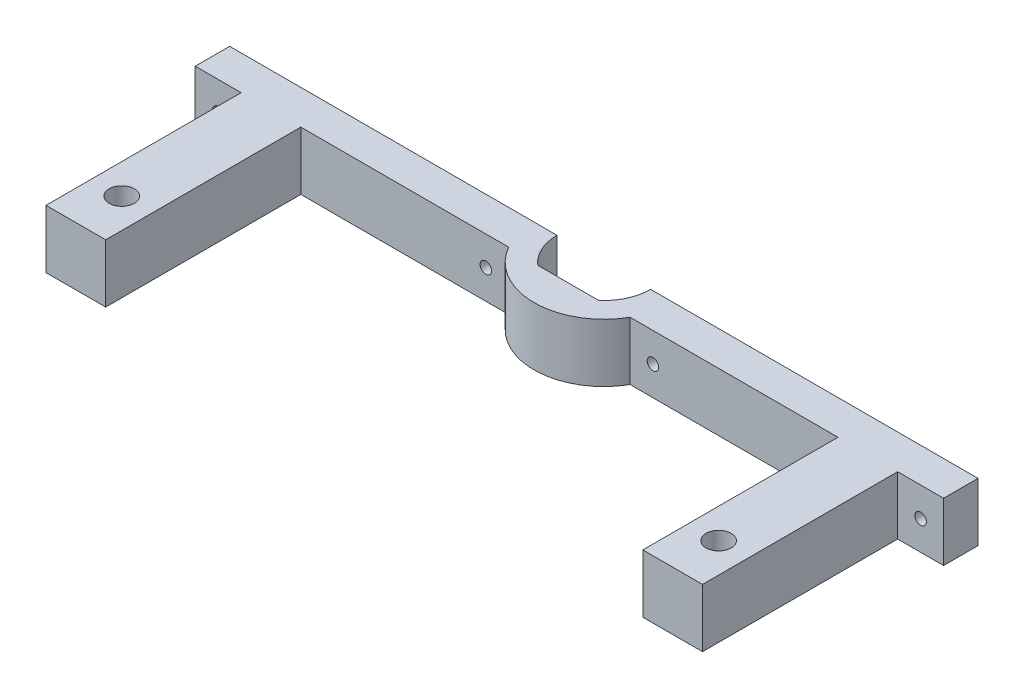
from build123d import *

# Parameters (mm, degrees)
SKETCH1_W           = 150
SKETCH1_H           = 100
BOSS_EXTRUDE1_DEPTH = 12.7
SKETCH2_W           = 13.263106726
SKETCH2_H           = 7.75
SKETCH2_R           = 2.75
CUT_EXTRUDE1_DEPTH  = 12.7
SKETCH3_R           = 2.75
CUT_EXTRUDE2_DEPTH  = 30
SKETCH5_W           = 7.5
SKETCH5_H           = 12.7
BOSS_EXTRUDE2_DEPTH = 10
SKETCH6_W           = 7.5
SKETCH6_H           = 12.7
BOSS_EXTRUDE3_DEPTH = 10
SKETCH4_R           = 1.25
CUT_EXTRUDE3_DEPTH  = 40


with BuildPart() as part:
    # Sketch1 → Boss-Extrude1 (new body)
    with BuildSketch(Plane(origin=(0, 0, 0), x_dir=(1, 0, 0), z_dir=(0, 1, 0))):
        with Locations((75, 50)):
            Rectangle(SKETCH1_W, SKETCH1_H)
    extrude(amount=BOSS_EXTRUDE1_DEPTH)

    # Sketch2 → Cut-Extrude1 (cut)
    with BuildSketch(Plane(origin=(0, 12.7, 0), x_dir=(1, 0, 0), z_dir=(0, 1, 0))):
        with BuildLine():
            ThreePointArc((81.631553363, 42.25), (84.265037623, 45.733962277), (85.2, 50))
            Line((85.2, 50), (81.631553363, 50))
            Line((81.631553363, 50), (81.631553363, 42.25))
        make_face()
        with BuildLine():
            Line((81.631553363, 50), (85.2, 50))
            ThreePointArc((85.2, 50), (84.265037623, 54.266037723), (81.631553363, 57.75))
            Line((81.631553363, 57.75), (81.631553363, 50))
        make_face()
        with BuildLine():
            Line((68.368446637, 42.25), (68.368446637, 50))
            Line((68.368446637, 50), (64.8, 50))
            ThreePointArc((64.8, 50), (65.734962377, 45.733962277), (68.368446637, 42.25))
        make_face()
        with BuildLine():
            Line((64.8, 50), (68.368446637, 50))
            Line((68.368446637, 50), (68.368446637, 57.75))
            ThreePointArc((68.368446637, 57.75), (65.734962377, 54.266037723), (64.8, 50))
        make_face()
        with Locations((75, 53.875)):
            Rectangle(SKETCH2_W, SKETCH2_H)
        with Locations((75, 46.125)):
            Rectangle(SKETCH2_W, SKETCH2_H)
        with Locations((10, 90)):
            Circle(SKETCH2_R)
        with Locations((140, 90)):
            Circle(SKETCH2_R)
        with Locations((140, 10)):
            Circle(SKETCH2_R)
        with Locations((10, 10)):
            Circle(SKETCH2_R)
    extrude(amount=-CUT_EXTRUDE1_DEPTH, mode=Mode.SUBTRACT)

    # Sketch3 → Cut-Extrude2 (cut)
    with BuildSketch(Plane(origin=(0, 12.7, 0), x_dir=(1, 0, 0), z_dir=(0, 1, 0))):
        with BuildLine():
            Line((133.5, 50), (146.5, 50))
            Line((146.5, 50), (146.5, 42.5))
            Line((146.5, 42.5), (146.5, 0))
            Line((146.5, 0), (150, 0))
            Line((150, 0), (150, 100))
            Line((150, 100), (0, 100))
            Line((0, 100), (0, 0))
            Line((0, 0), (3.5, 0))
            Line((3.5, 0), (3.5, 42.5))
            Line((3.5, 42.5), (3.5, 50))
            Line((3.5, 50), (16.5, 50))
            Line((16.5, 50), (59.8, 50))
            ThreePointArc((59.8, 50), (75, 65.2), (90.2, 50))
            Line((90.2, 50), (133.5, 50))
        make_face()
        with Locations((10, 90)):
            Circle(SKETCH3_R, mode=Mode.SUBTRACT)
        with Locations((140, 90)):
            Circle(SKETCH3_R, mode=Mode.SUBTRACT)
        with BuildLine():
            Line((85.2, 50), (90.2, 50))
            ThreePointArc((90.2, 50), (75, 65.2), (59.8, 50))
            Line((59.8, 50), (64.8, 50))
            ThreePointArc((64.8, 50), (65.734962377, 54.266037723), (68.368446637, 57.75))
            ThreePointArc((68.368446637, 57.75), (75, 60.2), (81.631553363, 57.75))
            ThreePointArc((81.631553363, 57.75), (84.265037623, 54.266037723), (85.2, 50))
        make_face()
        with BuildLine():
            Line((75, 50), (85.2, 50))
            ThreePointArc((85.2, 50), (84.265037623, 54.266037723), (81.631553363, 57.75))
            Line((81.631553363, 57.75), (68.368446637, 57.75))
            ThreePointArc((68.368446637, 57.75), (65.734962377, 54.266037723), (64.8, 50))
            Line((64.8, 50), (75, 50))
        make_face()
        with BuildLine():
            Line((133.5, 0), (133.5, 42.5))
            Line((133.5, 42.5), (88.220816919, 42.5))
            ThreePointArc((88.220816919, 42.5), (75, 34.8), (61.779183081, 42.5))
            Line((61.779183081, 42.5), (16.5, 42.5))
            Line((16.5, 42.5), (16.5, 0))
            Line((16.5, 0), (133.5, 0))
        make_face()
        with BuildLine():
            Line((75, 42.5), (75, 50))
            Line((75, 50), (64.8, 50))
            ThreePointArc((64.8, 50), (65.657812944, 45.90566965), (68.086968827, 42.5))
            Line((68.086968827, 42.5), (75, 42.5))
        make_face()
        with BuildLine():
            ThreePointArc((81.913031173, 42.5), (84.342187056, 45.90566965), (85.2, 50))
            Line((85.2, 50), (75, 50))
            Line((75, 50), (75, 42.5))
            Line((75, 42.5), (81.913031173, 42.5))
        make_face()
        with BuildLine():
            Line((68.368446637, 57.75), (81.631553363, 57.75))
            ThreePointArc((81.631553363, 57.75), (75, 60.2), (68.368446637, 57.75))
        make_face()
    extrude(amount=-CUT_EXTRUDE2_DEPTH, mode=Mode.SUBTRACT)

    # Sketch5 → Boss-Extrude2 (add)
    with BuildSketch(Plane(origin=(146.5, 0, 0), x_dir=(0, 0, -1), z_dir=(1, 0, 0))):
        with Locations((46.25, 6.35)):
            Rectangle(SKETCH5_W, SKETCH5_H)
    extrude(amount=BOSS_EXTRUDE2_DEPTH)

    # Sketch6 → Boss-Extrude3 (add)
    with BuildSketch(Plane.ZY.offset(-3.5)):
        with Locations((-46.25, 6.35)):
            Rectangle(SKETCH6_W, SKETCH6_H)
    extrude(amount=BOSS_EXTRUDE3_DEPTH)

    # Sketch4 → Cut-Extrude3 (cut)
    with BuildSketch(Plane(origin=(0, 0, -50), x_dir=(-1, 0, 0), z_dir=(0, 0, -1))):
        with Locations((-151.5, 6.35)):
            Circle(SKETCH4_R)
        with Locations((-93.2, 6.35)):
            Circle(SKETCH4_R)
        with Locations((-56.8, 6.35)):
            Circle(SKETCH4_R)
        with Locations((1.5, 6.35)):
            Circle(SKETCH4_R)
    extrude(amount=-CUT_EXTRUDE3_DEPTH, mode=Mode.SUBTRACT)


solid = part.part
